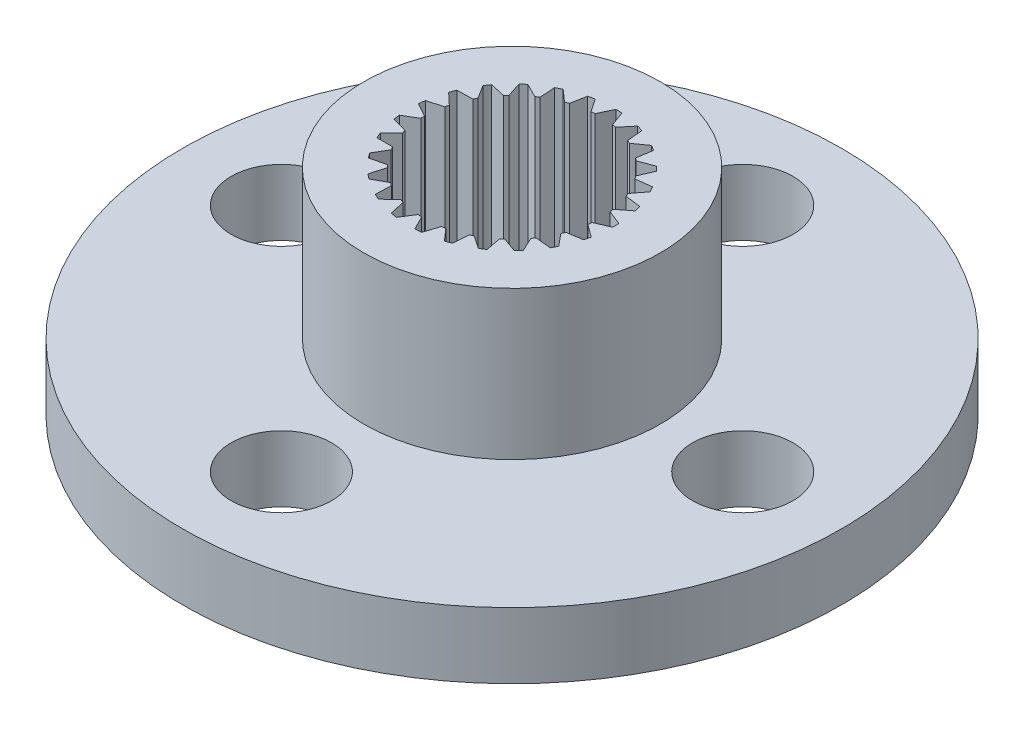
from build123d import *

# Parameters (mm, degrees)
SKETCH1_R           = 4.5
BOSS_EXTRUDE1_DEPTH = 6.5
SKETCH2_R           = 10
BOSS_EXTRUDE2_DEPTH = 2
SKETCH3_R           = 1.525
CUT_EXTRUDE1_DEPTH  = 7.5


with BuildPart() as part:
    # Sketch1 → Boss-Extrude1 (new body)
    with BuildSketch(Plane(origin=(24.301487189, 0, -59.250523978), x_dir=(0.955627849, 0, 0.29457667), z_dir=(0, -1, 0))):
        Circle(SKETCH1_R)
        with BuildLine():
            Line((-1.743463309, 2.563266606), (-1.337804671, 2.314678673))
            ThreePointArc((-1.337804671, 2.314678673), (-1.287955514, 2.342782383), (-1.237516253, 2.369812698))
            Line((-1.237516253, 2.369812698), (-1.230043219, 2.845521688))
            ThreePointArc((-1.230043219, 2.845521688), (-1.141186113, 2.882307106), (-1.05123072, 2.916318565))
            Line((-1.05123072, 2.916318565), (-0.7201379, 2.574657279))
            ThreePointArc((-0.7201379, 2.574657279), (-0.664865737, 2.589481077), (-0.609288952, 2.603118451))
            Line((-0.609288952, 2.603118451), (-0.483746682, 3.062023701))
            ThreePointArc((-0.483746682, 3.062023701), (-0.388533024, 3.075555574), (-0.292945439, 3.086127504))
            Line((-0.292945439, 3.086127504), (-0.057222215, 2.672860699))
            ThreePointArc((-0.057222215, 2.672860699), (0, 2.673473153), (0.057222215, 2.672860699))
            Line((0.057222215, 2.672860699), (0.292945439, 3.086127504))
            ThreePointArc((0.292945439, 3.086127504), (0.388533024, 3.075555574), (0.483746682, 3.062023701))
            Line((0.483746682, 3.062023701), (0.609288952, 2.603118451))
            ThreePointArc((0.609288952, 2.603118451), (0.664865737, 2.589481077), (0.7201379, 2.574657279))
            Line((0.7201379, 2.574657279), (1.05123072, 2.916318565))
            ThreePointArc((1.05123072, 2.916318565), (1.141186113, 2.882307106), (1.230043219, 2.845521688))
            Line((1.230043219, 2.845521688), (1.237516253, 2.369812698))
            ThreePointArc((1.237516253, 2.369812698), (1.287955514, 2.342782383), (1.337804671, 2.314678673))
            Line((1.337804671, 2.314678673), (1.743463309, 2.563266606))
            ThreePointArc((1.743463309, 2.563266606), (1.822134282, 2.507952683), (1.899051617, 2.450225083))
            Line((1.899051617, 2.450225083), (1.787985857, 1.987602897))
            ThreePointArc((1.787985857, 1.987602897), (1.830118309, 1.948878055), (1.871412256, 1.909260293))
            Line((1.871412256, 1.909260293), (2.326147686, 2.049155178))
            ThreePointArc((2.326147686, 2.049155178), (2.388591053, 1.976014368), (2.448735618, 1.900971824))
            Line((2.448735618, 1.900971824), (2.226109733, 1.480504696))
            ThreePointArc((2.226109733, 1.480504696), (2.257288041, 1.432518551), (2.287432125, 1.383876068))
            Line((2.287432125, 1.383876068), (2.762671649, 1.406287795))
            ThreePointArc((2.762671649, 1.406287795), (2.804963863, 1.319915804), (2.844556554, 1.232273514))
            Line((2.844556554, 1.232273514), (2.524358948, 0.88038094))
            ThreePointArc((2.524358948, 0.88038094), (2.542624063, 0.826148638), (2.559724222, 0.771537819))
            Line((2.559724222, 0.771537819), (3.025606792, 0.675058177))
            ThreePointArc((3.025606792, 0.675058177), (3.045090477, 0.580882075), (3.06164354, 0.486146927))
            Line((3.06164354, 0.486146927), (2.663993406, 0.224939612))
            ThreePointArc((2.663993406, 0.224939612), (2.668197664, 0.167868768), (2.671179432, 0.110721012))
            Line((2.671179432, 0.110721012), (3.098431932, -0.098587829))
            ThreePointArc((3.098431932, -0.098587829), (3.093882858, -0.194650611), (3.086356203, -0.290526059))
            Line((3.086356203, -0.290526059), (2.636239362, -0.444635499))
            ThreePointArc((2.636239362, -0.444635499), (2.626118593, -0.500958914), (2.614794614, -0.557052804))
            Line((2.614794614, -0.557052804), (2.9765712, -0.866039198))
            ThreePointArc((2.9765712, -0.866039198), (2.948275201, -0.957952683), (2.917141754, -1.048944224))
            Line((2.917141754, -1.048944224), (2.442840702, -1.086272527))
            ThreePointArc((2.442840702, -1.086272527), (2.419030833, -1.138309505), (2.394112634, -1.189824943))
            Line((2.394112634, -1.189824943), (2.667681551, -1.57907414))
            ThreePointArc((2.667681551, -1.57907414), (2.617416569, -1.661063064), (2.564632561, -1.741453366))
            Line((2.564632561, -1.741453366), (2.095949377, -1.659655056))
            ThreePointArc((2.095949377, -1.659655056), (2.059946468, -1.704135923), (2.022999752, -1.747836005))
            Line((2.022999752, -1.747836005), (2.19117166, -2.192890046))
            ThreePointArc((2.19117166, -2.192890046), (2.122096028, -2.259802745), (2.050978072, -2.324540589))
            Line((2.050978072, -2.324540589), (1.617361845, -2.128755355))
            ThreePointArc((1.617361845, -2.128755355), (1.571428092, -2.162885215), (1.524774356, -2.196024103))
            Line((1.524774356, -2.196024103), (1.576982395, -2.668918606))
            ThreePointArc((1.576982395, -2.668918606), (1.49343639, -2.716550708), (1.408453087, -2.761568377))
            Line((1.408453087, -2.761568377), (1.037149519, -2.464098126))
            ThreePointArc((1.037149519, -2.464098126), (0.984171108, -2.485732473), (0.930741779, -2.50622793))
            Line((0.930741779, -2.50622793), (0.863705526, -2.977249194))
            ThreePointArc((0.863705526, -2.977249194), (0.77093865, -3.002607799), (0.677429816, -3.025076668))
            Line((0.677429816, -3.025076668), (0.391769275, -2.644612549))
            ThreePointArc((0.391769275, -2.644612549), (0.335075035, -2.652392018), (0.278227274, -2.658956239))
            Line((0.278227274, -2.658956239), (0.096158863, -3.098508266))
            ThreePointArc((0.096158863, -3.098508266), (0, -3.1), (-0.096158863, -3.098508266))
            Line((-0.096158863, -3.098508266), (-0.278227274, -2.658956239))
            ThreePointArc((-0.278227274, -2.658956239), (-0.335075035, -2.652392018), (-0.391769275, -2.644612549))
            Line((-0.391769275, -2.644612549), (-0.677429816, -3.025076668))
            ThreePointArc((-0.677429816, -3.025076668), (-0.77093865, -3.002607799), (-0.863705526, -2.977249194))
            Line((-0.863705526, -2.977249194), (-0.930741779, -2.50622793))
            ThreePointArc((-0.930741779, -2.50622793), (-0.984171108, -2.485732473), (-1.037149519, -2.464098126))
            Line((-1.037149519, -2.464098126), (-1.408453087, -2.761568377))
            ThreePointArc((-1.408453087, -2.761568377), (-1.49343639, -2.716550708), (-1.576982395, -2.668918606))
            Line((-1.576982395, -2.668918606), (-1.524774356, -2.196024103))
            ThreePointArc((-1.524774356, -2.196024103), (-1.571428092, -2.162885215), (-1.617361845, -2.128755355))
            Line((-1.617361845, -2.128755355), (-2.050978072, -2.324540589))
            ThreePointArc((-2.050978072, -2.324540589), (-2.122096028, -2.259802745), (-2.19117166, -2.192890046))
            Line((-2.19117166, -2.192890046), (-2.022999752, -1.747836005))
            ThreePointArc((-2.022999752, -1.747836005), (-2.059946468, -1.704135923), (-2.095949377, -1.659655056))
            Line((-2.095949377, -1.659655056), (-2.564632561, -1.741453366))
            ThreePointArc((-2.564632561, -1.741453366), (-2.617416569, -1.661063064), (-2.667681551, -1.57907414))
            Line((-2.667681551, -1.57907414), (-2.394112634, -1.189824943))
            ThreePointArc((-2.394112634, -1.189824943), (-2.419030833, -1.138309505), (-2.442840702, -1.086272527))
            Line((-2.442840702, -1.086272527), (-2.917141754, -1.048944224))
            ThreePointArc((-2.917141754, -1.048944224), (-2.948275201, -0.957952683), (-2.9765712, -0.866039198))
            Line((-2.9765712, -0.866039198), (-2.614794614, -0.557052804))
            ThreePointArc((-2.614794614, -0.557052804), (-2.626118593, -0.500958914), (-2.636239362, -0.444635499))
            Line((-2.636239362, -0.444635499), (-3.086356203, -0.290526059))
            ThreePointArc((-3.086356203, -0.290526059), (-3.093882858, -0.194650611), (-3.098431932, -0.098587829))
            Line((-3.098431932, -0.098587829), (-2.671179432, 0.110721012))
            ThreePointArc((-2.671179432, 0.110721012), (-2.668197664, 0.167868768), (-2.663993406, 0.224939612))
            Line((-2.663993406, 0.224939612), (-3.06164354, 0.486146927))
            ThreePointArc((-3.06164354, 0.486146927), (-3.045090477, 0.580882075), (-3.025606792, 0.675058177))
            Line((-3.025606792, 0.675058177), (-2.559724222, 0.771537819))
            ThreePointArc((-2.559724222, 0.771537819), (-2.542624063, 0.826148638), (-2.524358948, 0.88038094))
            Line((-2.524358948, 0.88038094), (-2.844556554, 1.232273514))
            ThreePointArc((-2.844556554, 1.232273514), (-2.804963863, 1.319915804), (-2.762671649, 1.406287795))
            Line((-2.762671649, 1.406287795), (-2.287432125, 1.383876068))
            ThreePointArc((-2.287432125, 1.383876068), (-2.257288041, 1.432518551), (-2.226109733, 1.480504696))
            Line((-2.226109733, 1.480504696), (-2.448735618, 1.900971824))
            ThreePointArc((-2.448735618, 1.900971824), (-2.388591053, 1.976014368), (-2.326147686, 2.049155178))
            Line((-2.326147686, 2.049155178), (-1.871412256, 1.909260293))
            ThreePointArc((-1.871412256, 1.909260293), (-1.830118309, 1.948878055), (-1.787985857, 1.987602897))
            Line((-1.787985857, 1.987602897), (-1.899051617, 2.450225083))
            ThreePointArc((-1.899051617, 2.450225083), (-1.822134282, 2.507952683), (-1.743463309, 2.563266606))
        make_face(mode=Mode.SUBTRACT)
    extrude(amount=-BOSS_EXTRUDE1_DEPTH)

    # Sketch2 → Boss-Extrude2 (add)
    with BuildSketch(Plane(origin=(0, 0, 0), x_dir=(-1, 0, 0), z_dir=(0, -1, 0))):
        with Locations((-24.301487189, 59.250523978)):
            Circle(SKETCH2_R)
    extrude(amount=-BOSS_EXTRUDE2_DEPTH)

    # Sketch3 → Cut-Extrude1 (cut, through all)
    with BuildSketch(Plane(origin=(0, 0, 0), x_dir=(-1, 0, 0), z_dir=(0, -1, 0))):
        with Locations((-24.301487189, 66.250523978)):
            Circle(SKETCH3_R)
        with Locations((-17.301487189, 59.250523978)):
            Circle(SKETCH3_R)
        with Locations((-24.301487189, 52.250523978)):
            Circle(SKETCH3_R)
        with Locations((-31.301487189, 59.250523978)):
            Circle(SKETCH3_R)
    extrude(amount=-CUT_EXTRUDE1_DEPTH, mode=Mode.SUBTRACT)


solid = part.part
